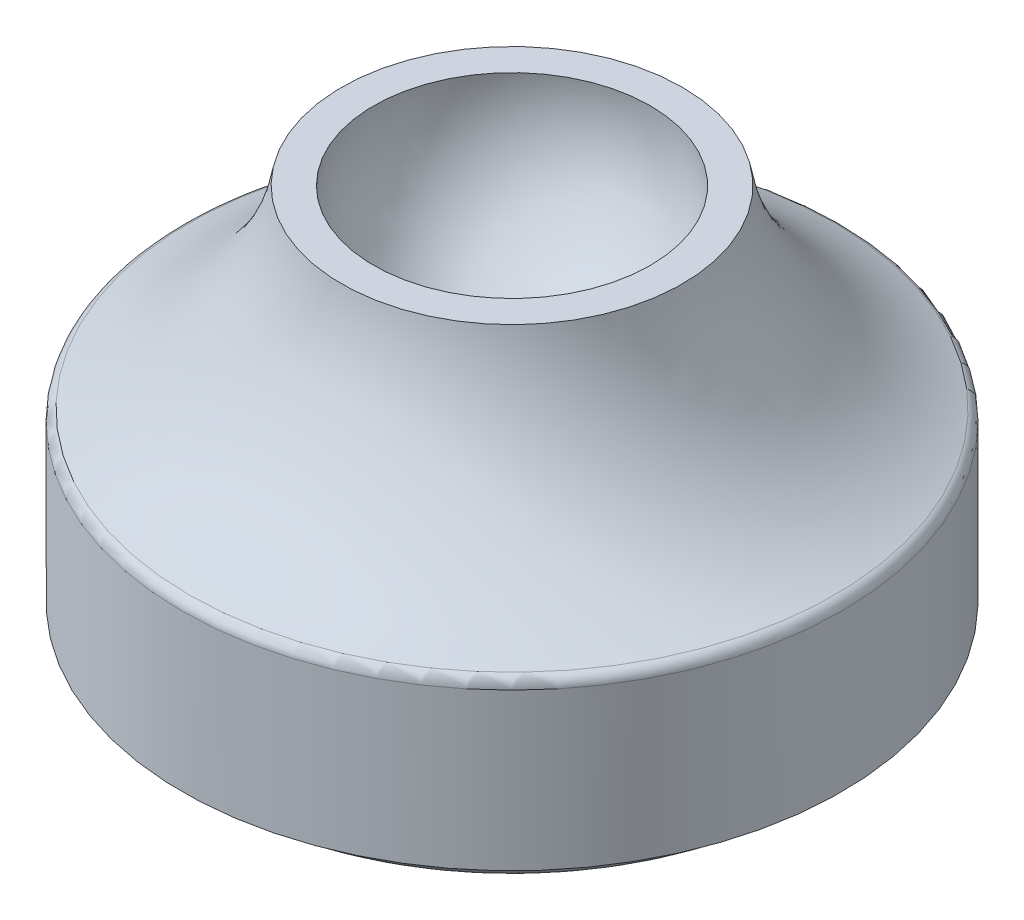
from build123d import *

# Parameters (mm, degrees)
FILLET1_R = 1


with BuildPart() as part:
    # Sketch1 → Revolve1 (revolve)
    with BuildSketch(Plane.XY):
        with BuildLine():
            Line((0, 0), (26.286199912, 0))
            Line((26.286199912, 0), (26.286199912, 2.410114973))
            Line((26.286199912, 2.410114973), (28.735209439, 2.410114973))
            Line((28.735209439, 2.410114973), (28.735209439, 16.726222584))
            ThreePointArc((28.735209439, 16.726222584), (19.520083074, 23.437939861), (14.857488789, 33.841108478))
            Line((14.857488789, 33.841108478), (12.063535171, 33.841108478))
            ThreePointArc((12.063535171, 33.841108478), (9.145229836, 24.235071542), (0, 20.092943721))
            Line((0, 20.092943721), (0, 0))
        make_face()
    revolve(axis=Axis((0, 0, 0), (0, 1, 0)))

    # Fillet1
    fillet1_edges = [part.edges().sort_by_distance(p)[0] for p in [
        (-28.735209439, 16.726222584, 0),
        (-26.286199912, 0, 0),
    ]]
    fillet(fillet1_edges, radius=FILLET1_R)


solid = part.part
